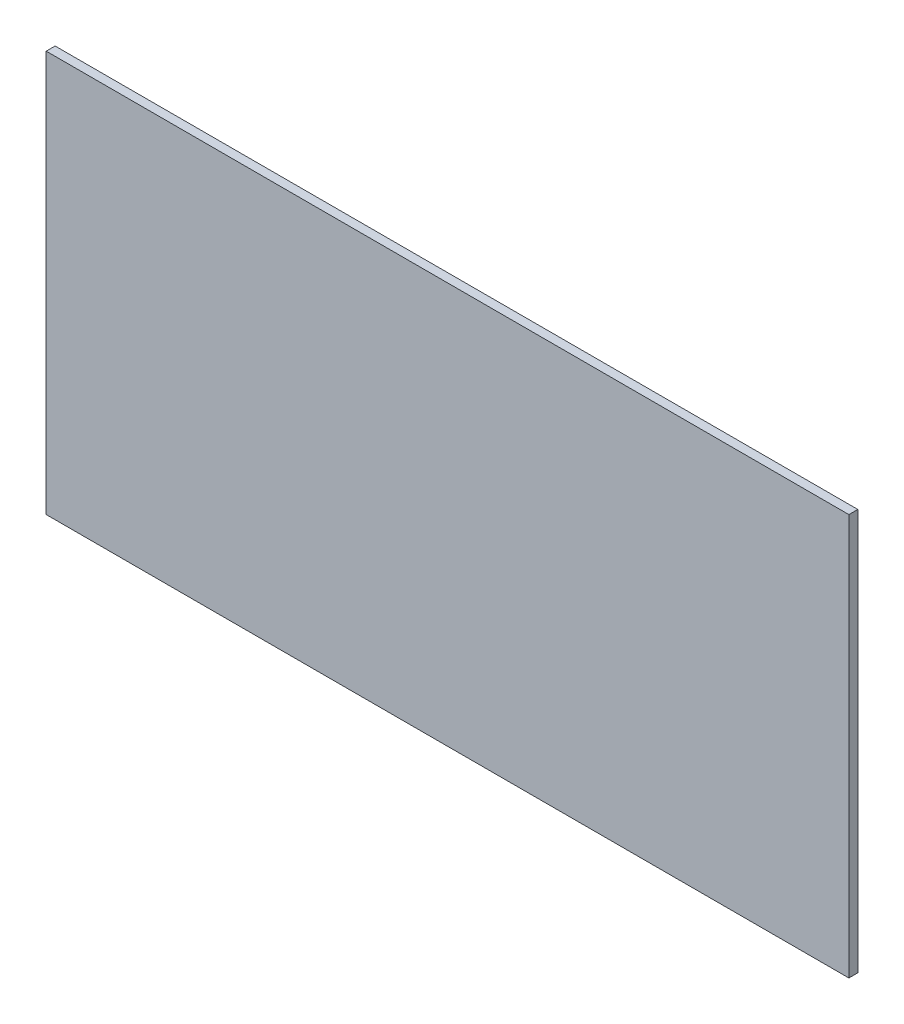
from build123d import *

# Parameters (mm, degrees)
SKETCH_1_W      = 180
SKETCH_1_H      = 90
EXTRUDE_1_DEPTH = 2


with BuildPart() as part:
    # 草图1 → 凸台-拉伸1 (new body)
    with BuildSketch(Plane.XY):
        Rectangle(SKETCH_1_W, SKETCH_1_H)
    extrude(amount=EXTRUDE_1_DEPTH)


solid = part.part
